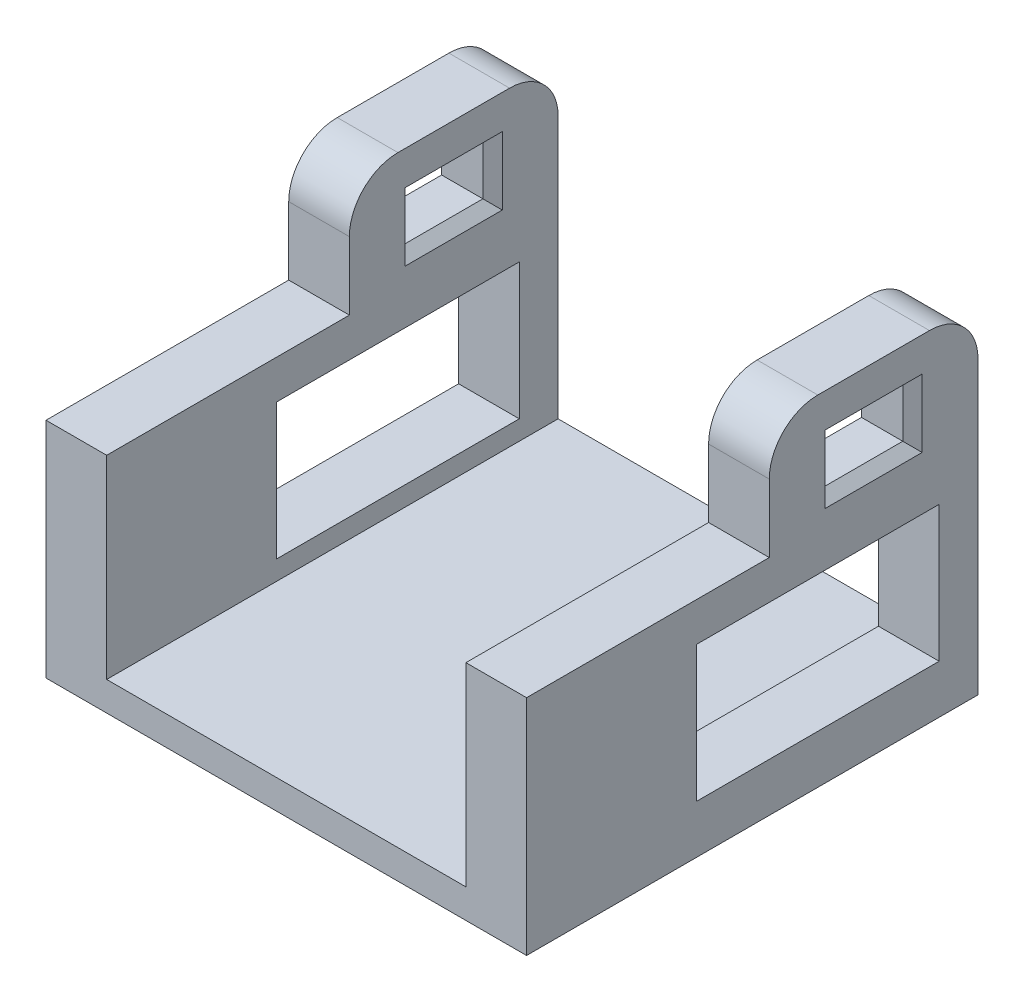
from build123d import *

# Parameters (mm, degrees)
SKETCH_1_W          = 49.5
SKETCH_1_H          = 21.5
EXTRUDE_1_DEPTH     = 3
SKETCH_4_W          = 6.25
SKETCH_4_H          = 21.5
EXTRUDE_2_DEPTH     = 20
EXTRUDE_3_DEPTH     = 25
SKETCH_7_W          = 6.25
SKETCH_7_H          = 21.5
EXTRUDE_4_DEPTH     = 12
SKETCH_8_W          = 8
SKETCH_8_H          = 5
CUT_EXTRUDE_1_DEPTH = 50.5
FILLET_1_R          = 5
FILLET_2_R          = 5
SKETCH_9_W          = 25
SKETCH_9_H          = 14
CUT_EXTRUDE_2_DEPTH = 50.5
CHAMFER_1_SIZE      = 1


with BuildPart() as part:
    # 草图1 → 凸台-拉伸1 (new body)
    with BuildSketch(Plane(origin=(0, 0, 0), x_dir=(1, 0, 0), z_dir=(0, 1, 0))):
        Rectangle(SKETCH_1_W, SKETCH_1_H)
    extrude(amount=EXTRUDE_1_DEPTH)

    # 草图4 → 凸台-拉伸2 (add)
    with BuildSketch(Plane(origin=(0, 3, 0), x_dir=(1, 0, 0), z_dir=(0, 1, 0))):
        with Locations((-21.625, 0)):
            Rectangle(SKETCH_4_W, SKETCH_4_H)
        with Locations((21.625, 0)):
            Rectangle(SKETCH_4_W, SKETCH_4_H)
    extrude(amount=EXTRUDE_2_DEPTH)

    # 草图6 → 凸台-拉伸3 (add)
    with BuildSketch(Plane.XY.offset(10.75)):
        Polygon((-24.75, 0), (24.75, 0), (24.75, 23), (18.5, 23), (18.5, 3), (-18.5, 3), (-18.5, 23), (-24.75, 23), align=None)
    extrude(amount=EXTRUDE_3_DEPTH)

    # 草图7 → 凸台-拉伸4 (add)
    with BuildSketch(Plane(origin=(0, 23, 0), x_dir=(1, 0, 0), z_dir=(0, 1, 0))):
        with Locations((-21.625, 0)):
            Rectangle(SKETCH_7_W, SKETCH_7_H)
        with Locations((21.625, 0)):
            Rectangle(SKETCH_7_W, SKETCH_7_H)
    extrude(amount=EXTRUDE_4_DEPTH)

    # 草图8 → 切除-拉伸1 (cut, through all)
    with BuildSketch(Plane(origin=(24.75, 0, 0), x_dir=(0, 0, -1), z_dir=(1, 0, 0))):
        with Locations((0, 28)):
            Rectangle(SKETCH_8_W, SKETCH_8_H)
    extrude(amount=-CUT_EXTRUDE_1_DEPTH, mode=Mode.SUBTRACT)

    # 圆角1
    fillet_1_edges = [part.edges().sort_by_distance(p)[0] for p in [
        (-21.625, 35, 10.75),
        (21.625, 35, 10.75),
    ]]
    fillet(fillet_1_edges, radius=FILLET_1_R)

    # 圆角2
    fillet_2_edges = [part.edges().sort_by_distance(p)[0] for p in [
        (-21.625, 35, -10.75),
        (21.625, 35, -10.75),
    ]]
    fillet(fillet_2_edges, radius=FILLET_2_R)

    # 草图9 → 切除-拉伸2 (cut, through all)
    with BuildSketch(Plane(origin=(24.75, 0, 0), x_dir=(0, 0, -1), z_dir=(1, 0, 0))):
        with Locations((-5.75, 12)):
            Rectangle(SKETCH_9_W, SKETCH_9_H)
    extrude(amount=-CUT_EXTRUDE_2_DEPTH, mode=Mode.SUBTRACT)

    # 倒角1
    chamfer_1_edges = [part.edges().sort_by_distance(p)[0] for p in [
        (18.5, 25.5, 0),
        (18.5, 28, -4),
        (18.5, 30.5, 0),
        (18.5, 28, 4),
        (-18.5, 28, 4),
        (-24.75, 28, 4),
        (-18.5, 30.5, 0),
        (-24.75, 30.5, 0),
        (-18.5, 28, -4),
        (-24.75, 28, -4),
        (-18.5, 25.5, 0),
        (-24.75, 25.5, 0),
        (24.75, 28, 4),
        (24.75, 25.5, 0),
        (24.75, 28, -4),
        (24.75, 30.5, 0),
    ]]
    chamfer(chamfer_1_edges, length=CHAMFER_1_SIZE)


solid = part.part
